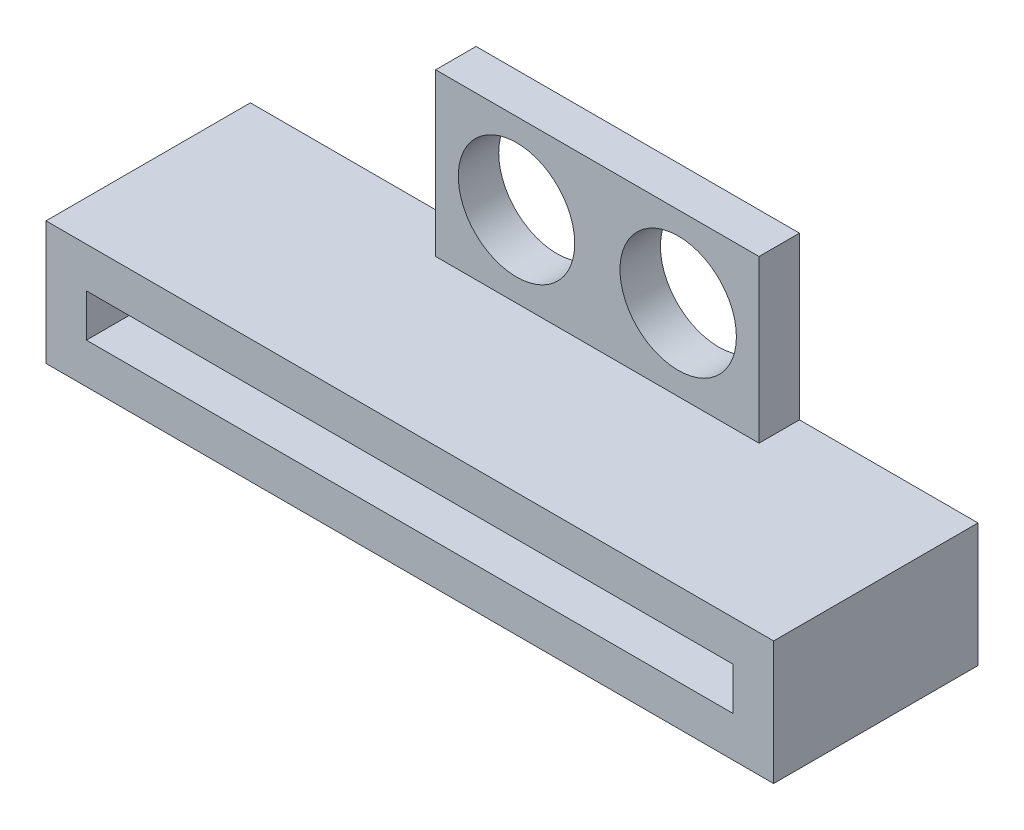
from build123d import *

# Parameters (mm, degrees)
SKETCH1_W           = 1.5875
SKETCH1_H           = 1.5875
BOSS_EXTRUDE1_DEPTH = 4.8514
SKETCH2_W           = 28.575
SKETCH2_H           = 4.8514
BOSS_EXTRUDE2_DEPTH = 3.175
SKETCH3_W           = 6.35
SKETCH3_H           = 1.5875
BOSS_EXTRUDE3_DEPTH = 6.35
SKETCH4_R           = 2.286
CUT_EXTRUDE1_DEPTH  = 6.35


with BuildPart() as part:
    # Sketch1 → Boss-Extrude1 (new body)
    with BuildSketch(Plane.XY):
        Polygon((0, 1.5875), (0, 0), (25.4, 0), (25.4, -1.6764), (26.9875, -1.6764), (26.9875, 1.5875), align=None)
        with Locations((-0.79375, 0.79375)):
            Rectangle(SKETCH1_W, SKETCH1_H)
        Polygon((0, -1.6764), (0, 0), (-1.5875, 0), (-1.5875, -3.2639), (25.4, -3.2639), (25.4, -1.6764), align=None)
        with Locations((26.19375, -2.47015)):
            Rectangle(SKETCH1_W, SKETCH1_H)
    extrude(amount=BOSS_EXTRUDE1_DEPTH)

    # Sketch2 → Boss-Extrude2 (add)
    with BuildSketch(Plane(origin=(0, 0, 0), x_dir=(-1, 0, 0), z_dir=(0, 0, -1))):
        with Locations((-12.7, -0.8382)):
            Rectangle(SKETCH2_W, SKETCH2_H)
    extrude(amount=BOSS_EXTRUDE2_DEPTH)

    # Sketch3 → Boss-Extrude3 (add)
    with BuildSketch(Plane(origin=(0, 1.5875, 0), x_dir=(1, 0, 0), z_dir=(0, 1, 0))):
        with Locations((16.80095606, 2.38125)):
            Rectangle(SKETCH3_W, SKETCH3_H)
        Polygon((13.62595606, 3.175), (12.7, 3.175), (7.27595606, 3.175), (7.27595606, 1.5875), (13.62595606, 1.5875), align=None)
    extrude(amount=BOSS_EXTRUDE3_DEPTH)

    # Sketch4 → Cut-Extrude1 (cut)
    with BuildSketch(Plane.XY.offset(-1.5875)):
        with BuildLine():
            ThreePointArc((19.08695606, 4.7625), (16.80095606, 7.0485), (14.51495606, 4.7625))
            Line((14.51495606, 4.7625), (19.08695606, 4.7625))
        make_face()
        with BuildLine():
            Line((19.08695606, 4.7625), (14.51495606, 4.7625))
            ThreePointArc((14.51495606, 4.7625), (16.80095606, 2.4765), (19.08695606, 4.7625))
        make_face()
        with Locations((10.45095606, 4.7625)):
            Circle(SKETCH4_R)
    extrude(amount=-CUT_EXTRUDE1_DEPTH, mode=Mode.SUBTRACT)


solid = part.part
